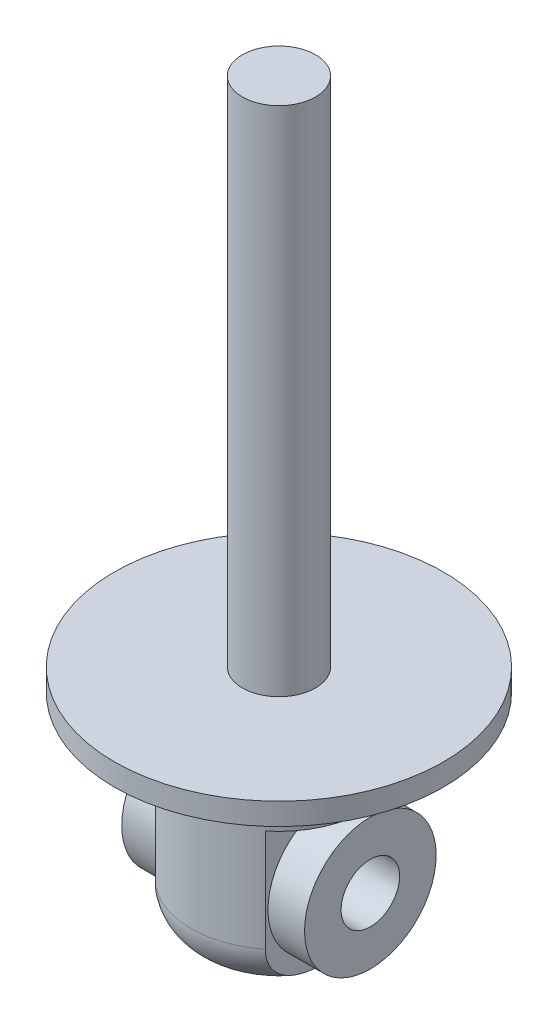
from build123d import *

# Parameters (mm, degrees)
SKETCH1_R               = 225
BOSS_EXTRUDE1_DEPTH     = 30
SKETCH2_R               = 50
BOSS_EXTRUDE2_DEPTH     = 700
SKETCH3_R               = 120
BOSS_EXTRUDE3_DEPTH     = 280
FILLET1_R               = 60
SKETCH4_W               = 195.7
SKETCH4_H               = 200
CUT_EXTRUDE1_DEPTH      = 226
CUT_EXTRUDE1_DEPTH_BACK = 226
SKETCH5_R               = 40
CUT_EXTRUDE2_DEPTH      = 301
SKETCH6_R               = 90
SKETCH6_R_2             = 40
BOSS_EXTRUDE4_DEPTH     = 125
SCALE1_SCALE            = 0.4


with BuildPart() as part:
    # Sketch1 → Boss-Extrude1 (new body)
    with BuildSketch(Plane(origin=(0, 0, 0), x_dir=(1, 0, 0), z_dir=(0, 1, 0))):
        Circle(SKETCH1_R)
    extrude(amount=BOSS_EXTRUDE1_DEPTH)

    # Sketch2 → Boss-Extrude2 (add)
    with BuildSketch(Plane(origin=(0, 30, 0), x_dir=(1, 0, 0), z_dir=(0, 1, 0))):
        Circle(SKETCH2_R)
    extrude(amount=BOSS_EXTRUDE2_DEPTH)

    # Sketch3 → Boss-Extrude3 (add)
    with BuildSketch(Plane.XZ):
        Circle(SKETCH3_R)
    extrude(amount=BOSS_EXTRUDE3_DEPTH)

    # Fillet1
    fillet1_edges = [part.edges().sort_by_distance(p)[0] for p in [
        (-120, -280, 0),
    ]]
    fillet(fillet1_edges, radius=FILLET1_R)

    # Sketch4 → Cut-Extrude1 (cut, two sides)
    with BuildSketch(Plane.XY) as cut_extrude1_sk:
        with Locations((172.85, -180)):
            Rectangle(SKETCH4_W, SKETCH4_H)
        with Locations((-172.85, -180)):
            Rectangle(SKETCH4_W, SKETCH4_H)
    extrude(amount=CUT_EXTRUDE1_DEPTH, mode=Mode.SUBTRACT)
    extrude(cut_extrude1_sk.sketch, amount=-CUT_EXTRUDE1_DEPTH_BACK, mode=Mode.SUBTRACT)

    # Sketch5 → Cut-Extrude2 (cut, through all)
    with BuildSketch(Plane(origin=(75, 0, 0), x_dir=(0, 0, -1), z_dir=(1, 0, 0))):
        with Locations((0, -175.331172544)):
            Circle(SKETCH5_R)
    extrude(amount=-CUT_EXTRUDE2_DEPTH, mode=Mode.SUBTRACT)

    # Sketch6 → Boss-Extrude4 (add, symmetric)
    with BuildSketch(Plane(origin=(0, 0, 0), x_dir=(0, 0, -1), z_dir=(1, 0, 0))):
        with Locations((0, -175.331172544)):
            Circle(SKETCH6_R)
        with Locations((0, -175.331172544)):
            Circle(SKETCH6_R_2, mode=Mode.SUBTRACT)
    extrude(amount=BOSS_EXTRUDE4_DEPTH, both=True)


with BuildPart() as part_1:
    # Scale1: scaled about (-3.146e-06, 30.247926965, -1.0493e-05)
    add(part.part.scale(SCALE1_SCALE).moved(Location((-1.888e-06, 18.148756179, -6.296e-06))))


solid = part_1.part
